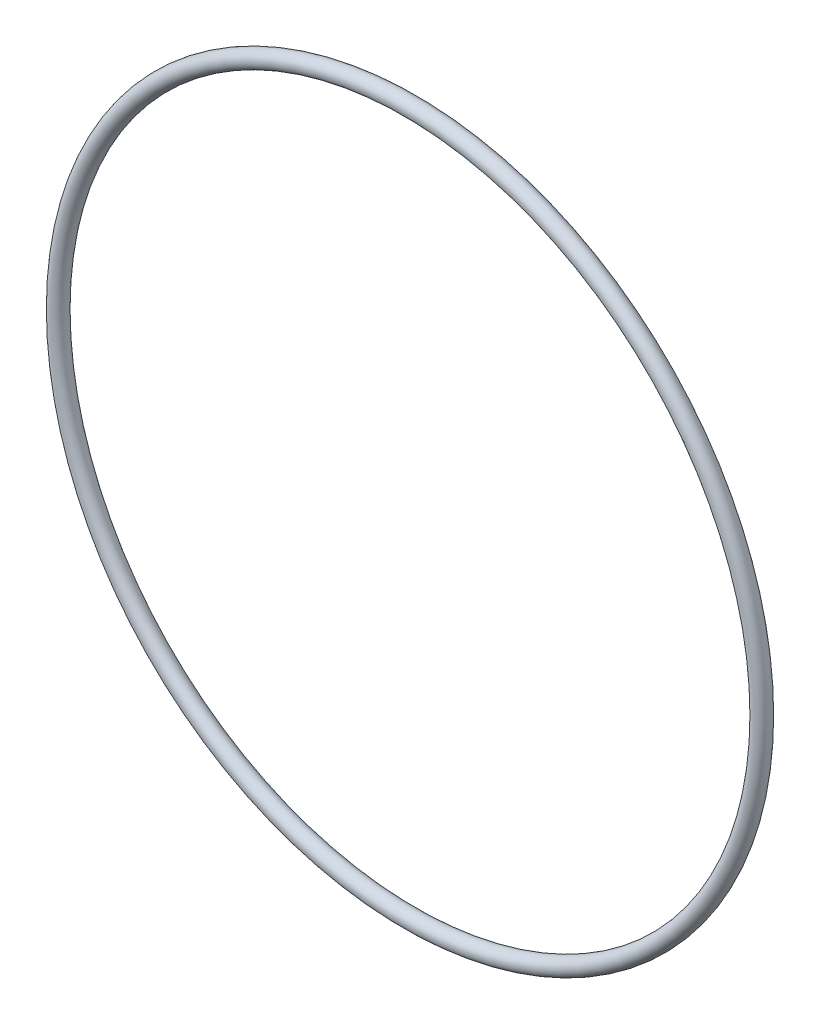
from build123d import *

# Parameters (mm, degrees)
SKETCH1_R = 0.889


with BuildPart() as part:
    # Sketch1 → Revolve1 (revolve)
    with BuildSketch(Plane(origin=(0, 0, 0), x_dir=(0, -1, 0), z_dir=(1, 0, 0))):
        with Locations((37.2618, 0)):
            Circle(SKETCH1_R)
    revolve(axis=Axis((0, 0, 0.889), (0, 0, -1)))


solid = part.part
